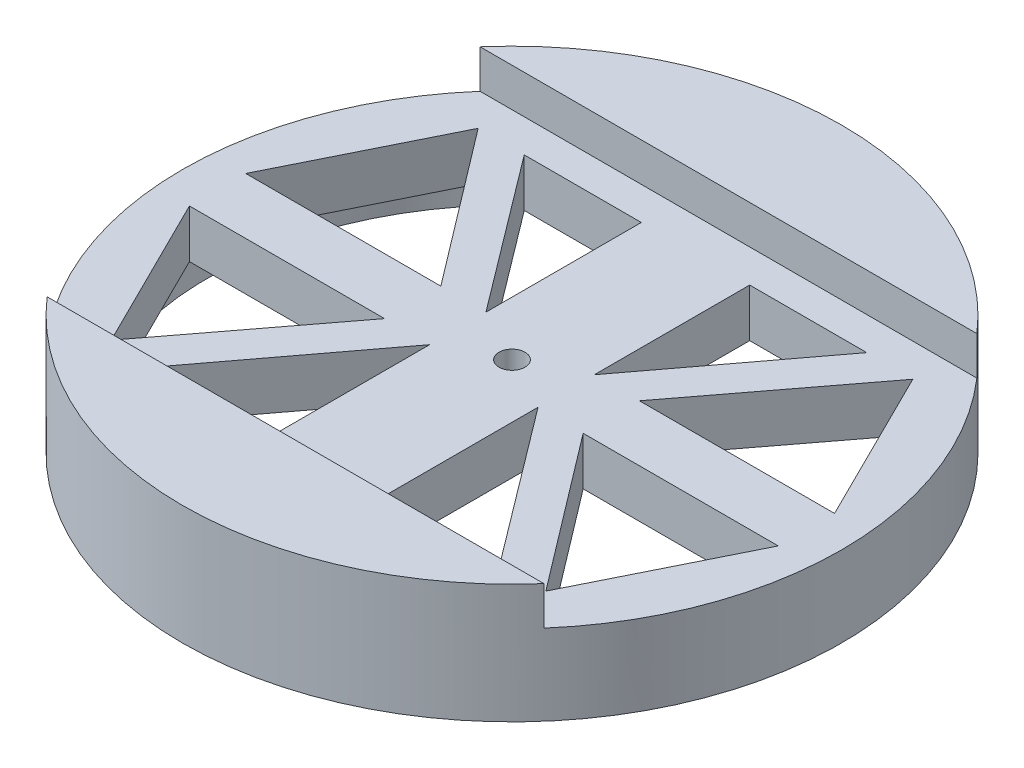
from build123d import *

# Parameters (mm, degrees)
SKETCH1_R           = 76
BOSS_EXTRUDE1_DEPTH = 27.5
CUT_EXTRUDE4_DEPTH  = 8.89
SKETCH5_R           = 3
CUT_EXTRUDE5_DEPTH  = 20
CUT_EXTRUDE6_DEPTH  = 19.61
CUT_EXTRUDE7_DEPTH  = 19.61
SKETCH13_R          = 70
CUT_EXTRUDE9_DEPTH  = 7.5


with BuildPart() as part:
    # Sketch1 → Boss-Extrude1 (new body)
    with BuildSketch(Plane(origin=(0, 0, 0), x_dir=(1, 0, 0), z_dir=(0, 1, 0))):
        Circle(SKETCH1_R)
    extrude(amount=BOSS_EXTRUDE1_DEPTH)

    # Sketch2 → Cut-Extrude4 (cut)
    with BuildSketch(Plane(origin=(0, 27.5, 0), x_dir=(1, 0, 0), z_dir=(0, 1, 0))):
        with BuildLine():
            Line((-58.007955522, 49.931796385), (58.007955522, 49.931796385))
            ThreePointArc((58.007955522, 49.931796385), (107.939751907, 0), (58.007955522, -49.931796385))
            Line((58.007955522, -49.931796385), (-58.007955522, -49.931796385))
            ThreePointArc((-58.007955522, -49.931796385), (-107.939751907, 0), (-58.007955522, 49.931796385))
        make_face()
    extrude(amount=-CUT_EXTRUDE4_DEPTH, mode=Mode.SUBTRACT)

    # Sketch5 → Cut-Extrude5 (cut)
    with BuildSketch(Plane(origin=(0, 18.61, 0), x_dir=(1, 0, 0), z_dir=(0, 1, 0))):
        Circle(SKETCH5_R)
    extrude(amount=-CUT_EXTRUDE5_DEPTH, mode=Mode.SUBTRACT)

    # Sketch7 → Cut-Extrude6 (cut, through all)
    with BuildSketch(Plane(origin=(0, 18.61, 0), x_dir=(1, 0, 0), z_dir=(0, 1, 0))):
        Polygon((-50.125135648, 42.322849323), (-67.902913426, 6.490592664), (-22.902913426, 6.490592664), align=None)
        Polygon((67.902913426, 6.490592664), (22.902913426, 6.490592664), (50.125135648, 42.322849323), align=None)
        Polygon((50.125135648, -42.322849323), (67.902913426, -6.490592664), (22.902913426, -6.490592664), align=None)
        Polygon((-67.902913426, -6.490592664), (-22.902913426, -6.490592664), (-50.125135648, -42.322849323), align=None)
    extrude(amount=-CUT_EXTRUDE6_DEPTH, mode=Mode.SUBTRACT)

    # Sketch9 → Cut-Extrude7 (cut, through all)
    with BuildSketch(Plane(origin=(0, 18.61, 0), x_dir=(1, 0, 0), z_dir=(0, 1, 0))):
        Polygon((-12.5, 6.490592664), (-12.5, 42.322849323), (-39.5, 42.322849323), align=None)
        Polygon((12.5, 6.490592664), (39.5, 42.322849323), (12.5, 42.322849323), align=None)
        Polygon((12.5, -6.490592664), (12.5, -42.322849323), (39.5, -42.322849323), align=None)
        Polygon((-12.5, -6.490592664), (-39.5, -42.322849323), (-12.5, -42.322849323), align=None)
    extrude(amount=-CUT_EXTRUDE7_DEPTH, mode=Mode.SUBTRACT)

    # Sketch13 → Cut-Extrude9 (cut)
    with BuildSketch(Plane(origin=(0, 0, 0), x_dir=(-1, 0, 0), z_dir=(0, -1, 0))):
        Circle(SKETCH13_R)
    extrude(amount=-CUT_EXTRUDE9_DEPTH, mode=Mode.SUBTRACT)


solid = part.part
